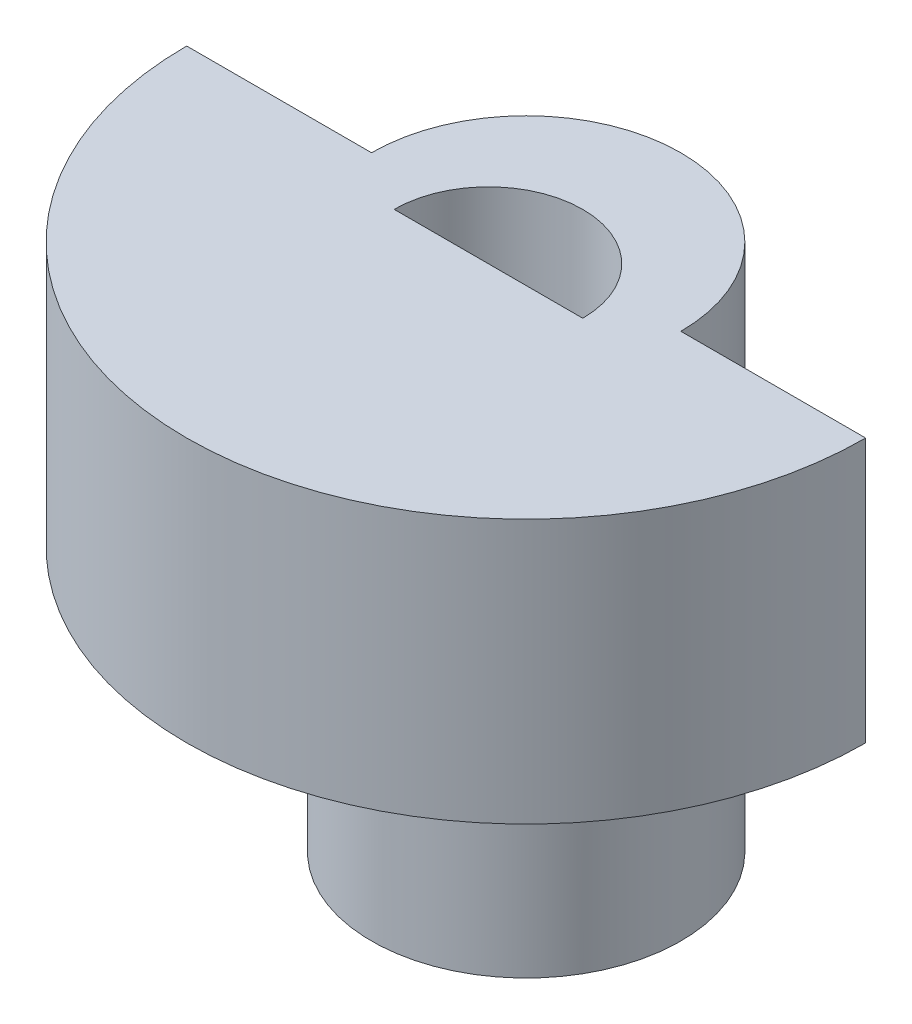
from build123d import *

# Parameters (mm, degrees)
BOSS_EXTRUDE1_DEPTH = 7
SKETCH2_R           = 4.1
BOSS_EXTRUDE2_DEPTH = 7
CUT_EXTRUDE1_DEPTH  = 15


with BuildPart() as part:
    # Sketch1 → Boss-Extrude1 (new body)
    with BuildSketch(Plane(origin=(0, 0, 0), x_dir=(1, 0, 0), z_dir=(0, 1, 0))):
        with BuildLine():
            Line((4.1, 0), (9, 0))
            ThreePointArc((9, 0), (0, -9), (-9, 0))
            Line((-9, 0), (-4.1, 0))
            ThreePointArc((-4.1, 0), (0, 4.1), (4.1, 0))
        make_face()
    extrude(amount=BOSS_EXTRUDE1_DEPTH)

    # Sketch2 → Boss-Extrude2 (add)
    with BuildSketch(Plane.XZ):
        Circle(SKETCH2_R)
    extrude(amount=BOSS_EXTRUDE2_DEPTH)

    # Sketch3 → Cut-Extrude1 (cut, through all)
    with BuildSketch(Plane(origin=(0, 7, 0), x_dir=(1, 0, 0), z_dir=(0, 1, 0))):
        with BuildLine():
            Line((2.5, -1), (-2.5, -1))
            ThreePointArc((-2.5, -1), (0, 1.5), (2.5, -1))
        make_face()
    extrude(amount=-CUT_EXTRUDE1_DEPTH, mode=Mode.SUBTRACT)


solid = part.part
